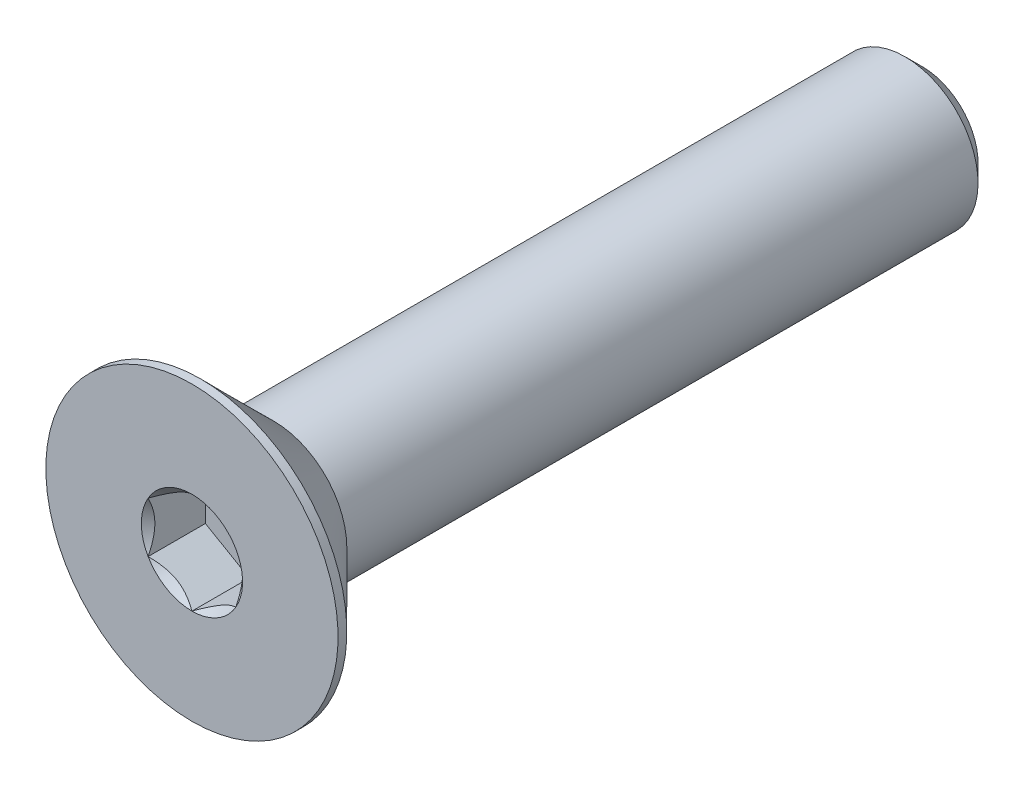
from build123d import *

# Parameters (mm, degrees)
SKETCH1_W          = 25
SKETCH1_H          = 2.5
CHAMFER1_SIZE      = 0.6
CUT_EXTRUDE2_DEPTH = 1.96


with BuildPart() as part:
    # Sketch1 → Revolve1 (revolve)
    with BuildSketch(Plane(origin=(0, 0, 0), x_dir=(0, 0, -1), z_dir=(1, 0, 0))):
        with Locations((12.5, 1.25)):
            Rectangle(SKETCH1_W, SKETCH1_H)
    revolve(axis=Axis((0, 0, -25), (0, 0, 1)))

    # Chamfer1
    chamfer1_edges = [part.edges().sort_by_distance(p)[0] for p in [
        (0, -2.5, -25),
    ]]
    chamfer(chamfer1_edges, length=CHAMFER1_SIZE)

    # Sketch7 → Revolve2 (revolve)
    with BuildSketch(Plane(origin=(0, 0, 0), x_dir=(0, 0, -1), z_dir=(1, 0, 0)), mode=Mode.PRIVATE) as revolve2_sk:
        Polygon((0, 5), (0.3, 5), (2.8, 2.5), (2.8, 0), (0, 0), align=None)
    revolve(revolve2_sk.sketch.rotate(Axis((0, 0, 0), (0, 0, -1)), 180), axis=Axis((0, 0, 0), (0, 0, -1)))

    # Boss-Extrude1 cone 1 section (through the dimple's axis) → Boss-Extrude1 (revolve)
    with BuildSketch(Plane(origin=(0, 0, -2.8), x_dir=(0, -1, 0), z_dir=(1, 0, 0))):
        Polygon((0, 0), (2.5, 0), (0, 2.5), align=None)
    revolve(axis=Axis((0, 0, -2.8), (0, 0, -1)))

    # Sketch5 → Cut-Extrude2 (cut)
    with BuildSketch(Plane.XY):
        Polygon((1.5, -0.866025404), (1.5, 0.866025404), (0, 1.732050808), (-1.5, 0.866025404), (-1.5, -0.866025404), (0, -1.732050808), align=None)
    extrude(amount=-CUT_EXTRUDE2_DEPTH, mode=Mode.SUBTRACT)

    # Cut-Extrude3 cone 1 section (through the dimple's axis) → Cut-Extrude3 (revolve, cut)
    with BuildSketch(Plane(origin=(0, 0, 0), x_dir=(0, -1, 0), z_dir=(1, 0, 0))):
        Polygon((0, 0), (1.732050808, 0), (0, 1.732050808), align=None)
    revolve(axis=Axis((0, 0, 0), (0, 0, -1)), mode=Mode.SUBTRACT)


solid = part.part
